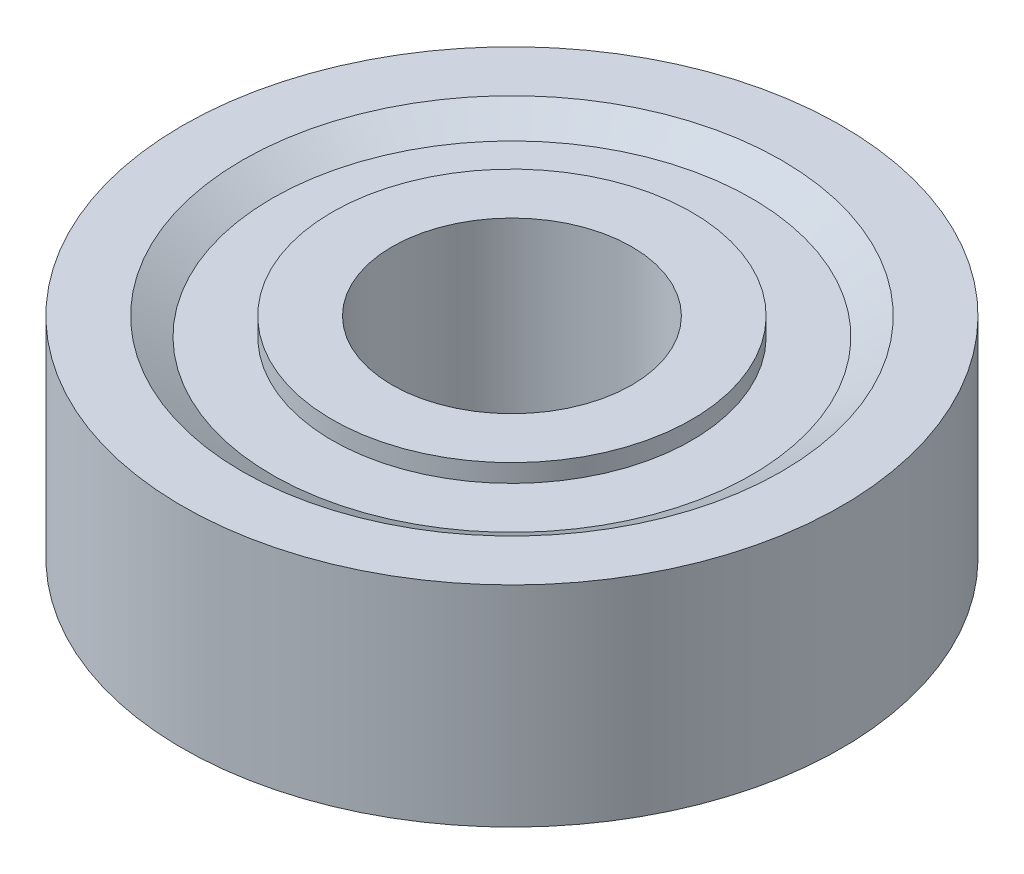
from build123d import *


with BuildPart() as part:
    # Çizim1 → Döndür1 (revolve)
    with BuildSketch(Plane.XY):
        Polygon((-3.719958812, 0), (-4.719958812, -0.6), (-6.719958812, -0.6), (-6.719958812, 6.4), (-4.719958812, 6.4), (-3.719958812, 5.8), (-1.719958812, 5.8), (-1.719958812, 6.4), (0.280041188, 6.4), (0.280041188, -0.6), (-1.719958812, -0.6), (-1.719958812, 0), align=None)
    revolve(axis=Axis((4.280041188, 8.162742968, 0), (0, -1, 0)))


solid = part.part
